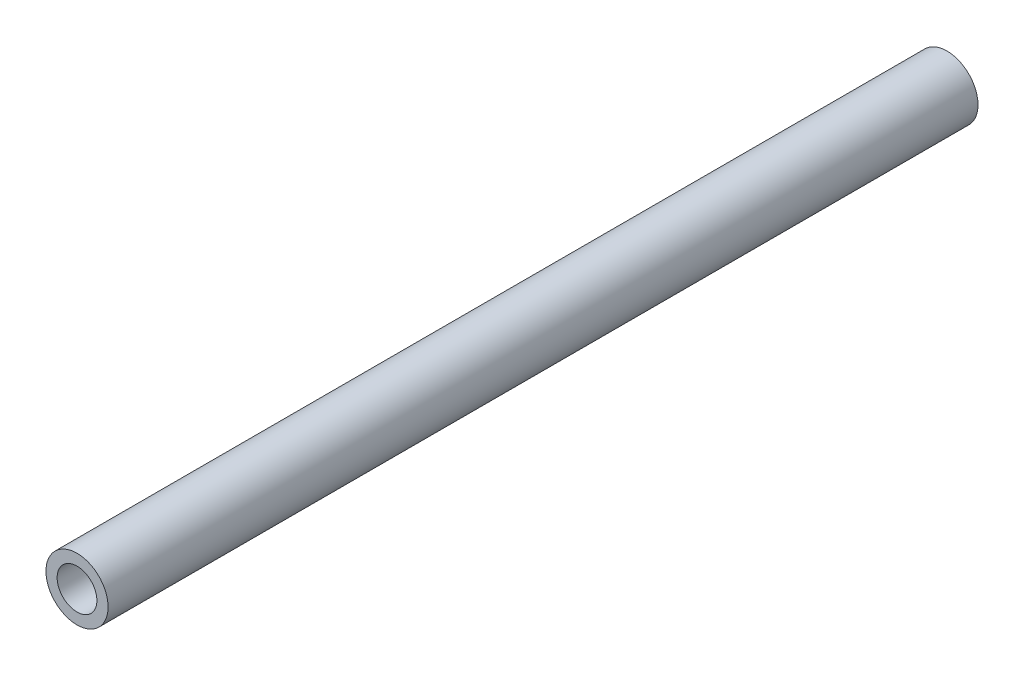
from build123d import *

# Parameters (mm, degrees)
SKETCH1_R           = 2.5
SKETCH1_R_2         = 1.6
BOSS_EXTRUDE1_DEPTH = 70


with BuildPart() as part:
    # Sketch1 → Boss-Extrude1 (new body)
    with BuildSketch(Plane.XY):
        Circle(SKETCH1_R)
        Circle(SKETCH1_R_2, mode=Mode.SUBTRACT)
    extrude(amount=BOSS_EXTRUDE1_DEPTH)


solid = part.part
